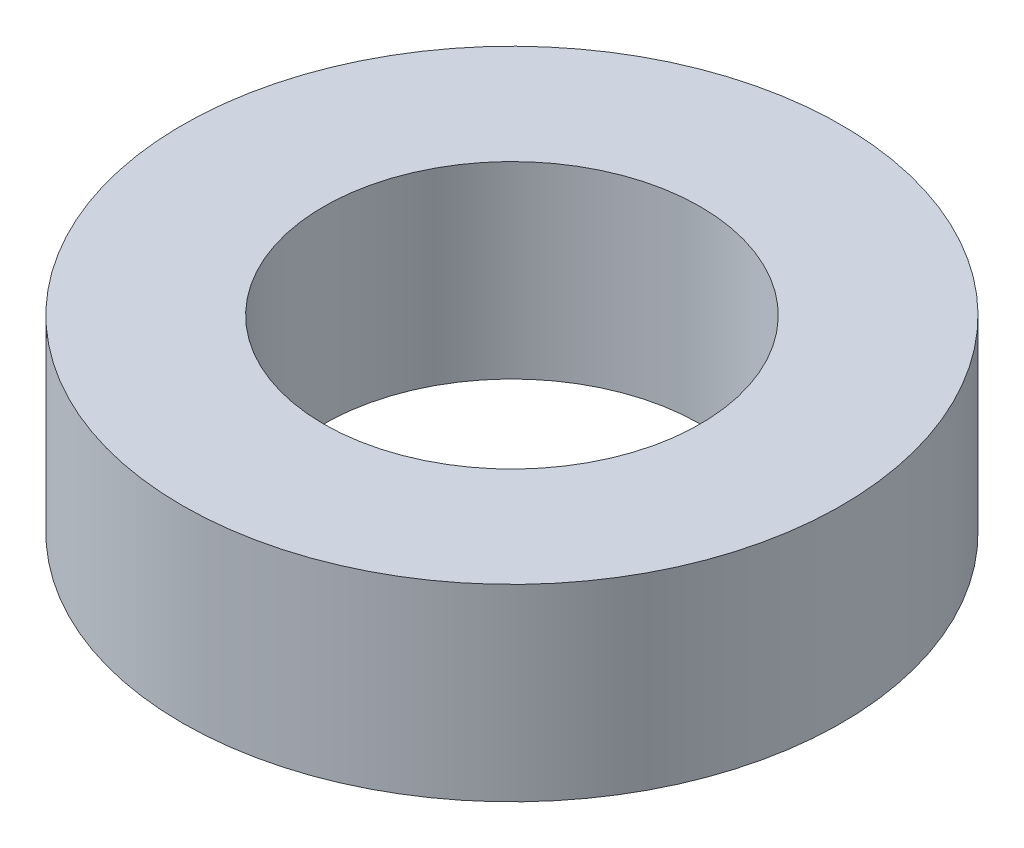
from build123d import *

# Parameters (mm, degrees)
SKETCH1_R           = 2.778125
SKETCH1_R_2         = 1.5875
BOSS_EXTRUDE1_DEPTH = 1.5875


with BuildPart() as part:
    # Sketch1 → Boss-Extrude1 (new body)
    with BuildSketch(Plane(origin=(0, 0, 0), x_dir=(1, 0, 0), z_dir=(0, 1, 0))):
        Circle(SKETCH1_R)
        Circle(SKETCH1_R_2, mode=Mode.SUBTRACT)
    extrude(amount=BOSS_EXTRUDE1_DEPTH)


solid = part.part
